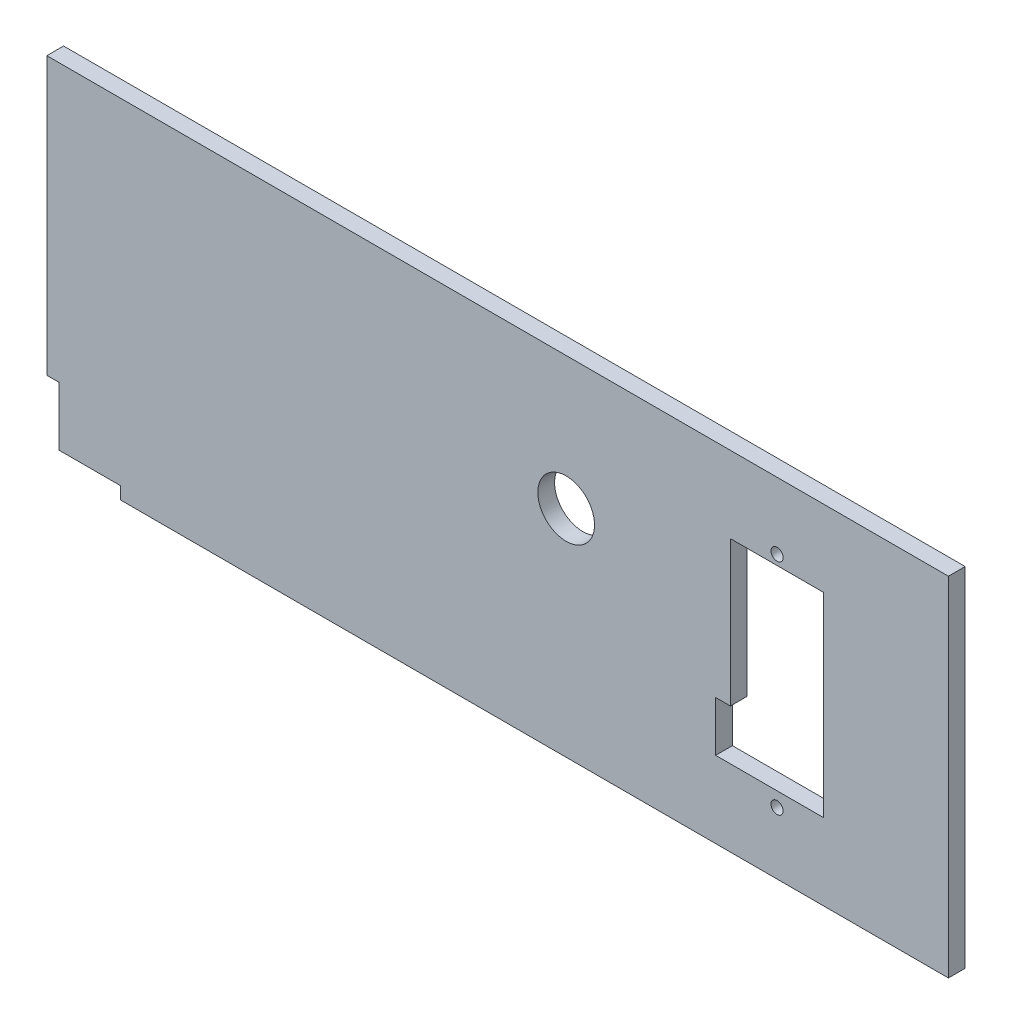
from build123d import *

# Parameters (mm, degrees)
SKETCH1_R           = 2.3
SKETCH1_R_2         = 10.75
BOSS_EXTRUDE1_DEPTH = 6.35


with BuildPart() as part:
    # Sketch1 → Boss-Extrude1 (new body)
    with BuildSketch(Plane.XY):
        Polygon((-1, 138), (341, 138), (341, 6), (27, 6), (27, 10.7), (3.7, 10.7), (3.7, 33), (-1, 33), align=None)
        with Locations((276, 112.7)):
            Circle(SKETCH1_R, mode=Mode.SUBTRACT)
        with Locations((276, 29.5)):
            Circle(SKETCH1_R, mode=Mode.SUBTRACT)
        with Locations((196, 87.7)):
            Circle(SKETCH1_R_2, mode=Mode.SUBTRACT)
        Polygon((293.7, 35), (252.7, 35), (252.7, 54), (258.3, 54), (258.3, 109), (293.7, 109), align=None, mode=Mode.SUBTRACT)
    extrude(amount=BOSS_EXTRUDE1_DEPTH)


solid = part.part
